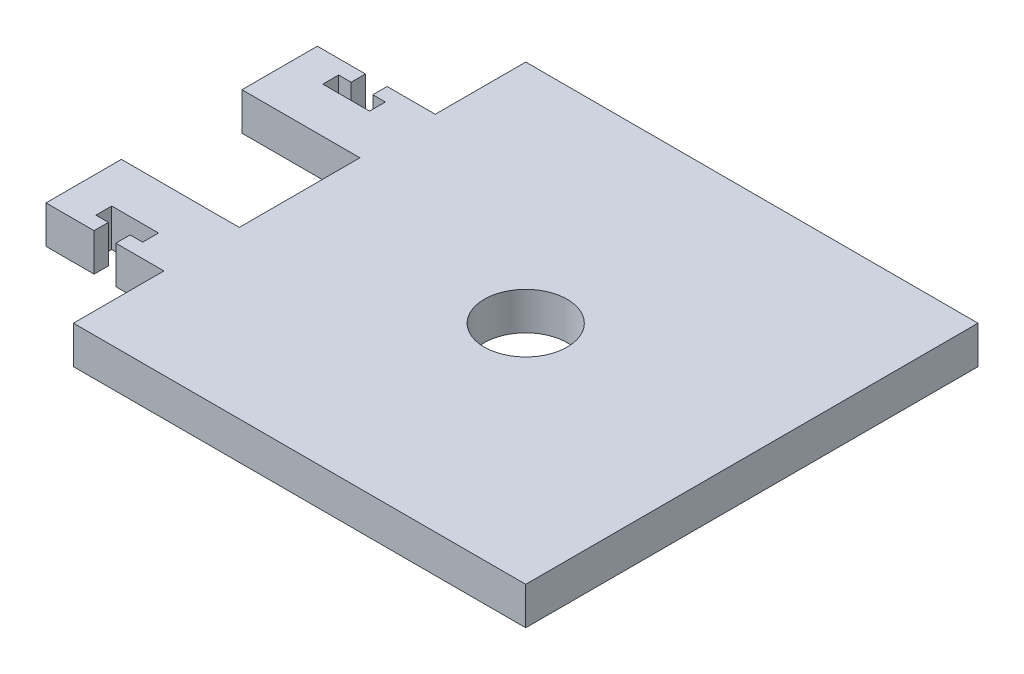
from build123d import *

# Parameters (mm, degrees)
SKETCH1_R           = 6.985
BOSS_EXTRUDE1_DEPTH = 6.35


with BuildPart() as part:
    # Sketch1 → Boss-Extrude1 (new body)
    with BuildSketch(Plane(origin=(0, 0, 0), x_dir=(1, 0, 0), z_dir=(0, 1, 0))):
        Polygon((-38.1, -38.1), (38.1, -38.1), (38.1, 38.1), (-38.1, 38.1), (-38.1, 22.86), (-46.2026, 22.86), (-46.2026, 20.447), (-44.0944, 20.447), (-44.0944, 17.78), (-51.9684, 17.78), (-51.9684, 20.447), (-49.8602, 20.447), (-49.8602, 22.86), (-57.9628, 22.86), (-57.9628, 10.16), (-38.1, 10.16), (-38.1, -10.16), (-57.9628, -10.16), (-57.9628, -22.86), (-49.8602, -22.86), (-49.8602, -20.447), (-51.9684, -20.447), (-51.9684, -17.78), (-44.0944, -17.78), (-44.0944, -20.447), (-46.2026, -20.447), (-46.2026, -22.86), (-38.1, -22.86), align=None)
        Circle(SKETCH1_R, mode=Mode.SUBTRACT)
    extrude(amount=-BOSS_EXTRUDE1_DEPTH)


solid = part.part
